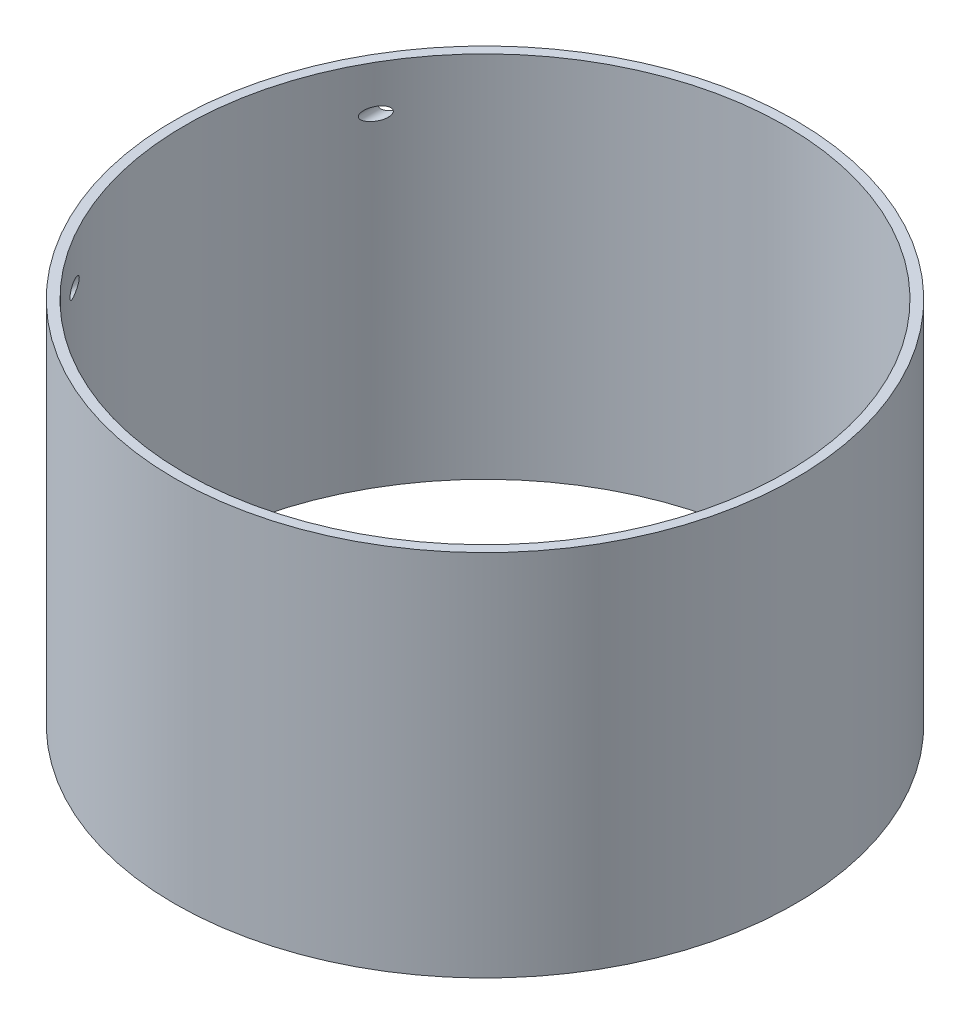
from build123d import *

# Parameters (mm, degrees)
SKETCH1_R               = 101.6
SKETCH1_R_2             = 95.25
BOSS_EXTRUDE1_DEPTH     = 25.4
SKETCH2_R               = 3.175
CUT_EXTRUDE1_DEPTH      = 102.6
CUT_EXTRUDE1_DEPTH_BACK = 102.6
SKETCH5_R               = 101.6
SKETCH5_R_2             = 98.425
BOSS_EXTRUDE2_DEPTH     = 146.05
SKETCH9_R               = 2.1
CUT_EXTRUDE5_DEPTH      = 204.2000001
SKETCH10_R              = 101.6
CUT_EXTRUDE6_DEPTH      = 50.8


with BuildPart() as part:
    # Sketch1 → Boss-Extrude1 (new body)
    with BuildSketch(Plane(origin=(0, 0, 0), x_dir=(1, 0, 0), z_dir=(0, 1, 0))):
        Circle(SKETCH1_R)
        Circle(SKETCH1_R_2, mode=Mode.SUBTRACT)
    extrude(amount=BOSS_EXTRUDE1_DEPTH)

    # Sketch2 → Cut-Extrude1 (cut, two sides)
    with BuildSketch(Plane.XY) as cut_extrude1_sk:
        with Locations((0, 12.7)):
            Circle(SKETCH2_R)
    extrude(amount=CUT_EXTRUDE1_DEPTH, mode=Mode.SUBTRACT)
    extrude(cut_extrude1_sk.sketch, amount=-CUT_EXTRUDE1_DEPTH_BACK, mode=Mode.SUBTRACT)

    # Sketch5 → Boss-Extrude2 (add)
    with BuildSketch(Plane(origin=(0, 25.4, 0), x_dir=(1, 0, 0), z_dir=(0, 1, 0))):
        Circle(SKETCH5_R)
        Circle(SKETCH5_R_2, mode=Mode.SUBTRACT)
    extrude(amount=BOSS_EXTRUDE2_DEPTH)

    # Sketch9 → Cut-Extrude5 (cut, through all)
    with BuildSketch(Plane.XY.offset(101.6)):
        with Locations((-85.075, 156.8)):
            Circle(SKETCH9_R)
    extrude(amount=-CUT_EXTRUDE5_DEPTH, mode=Mode.SUBTRACT)

    # Sketch10 → Cut-Extrude6 (cut)
    with BuildSketch(Plane(origin=(0, 0, 0), x_dir=(-1, 0, 0), z_dir=(0, -1, 0))):
        Circle(SKETCH10_R)
    extrude(amount=-CUT_EXTRUDE6_DEPTH, mode=Mode.SUBTRACT)


solid = part.part
